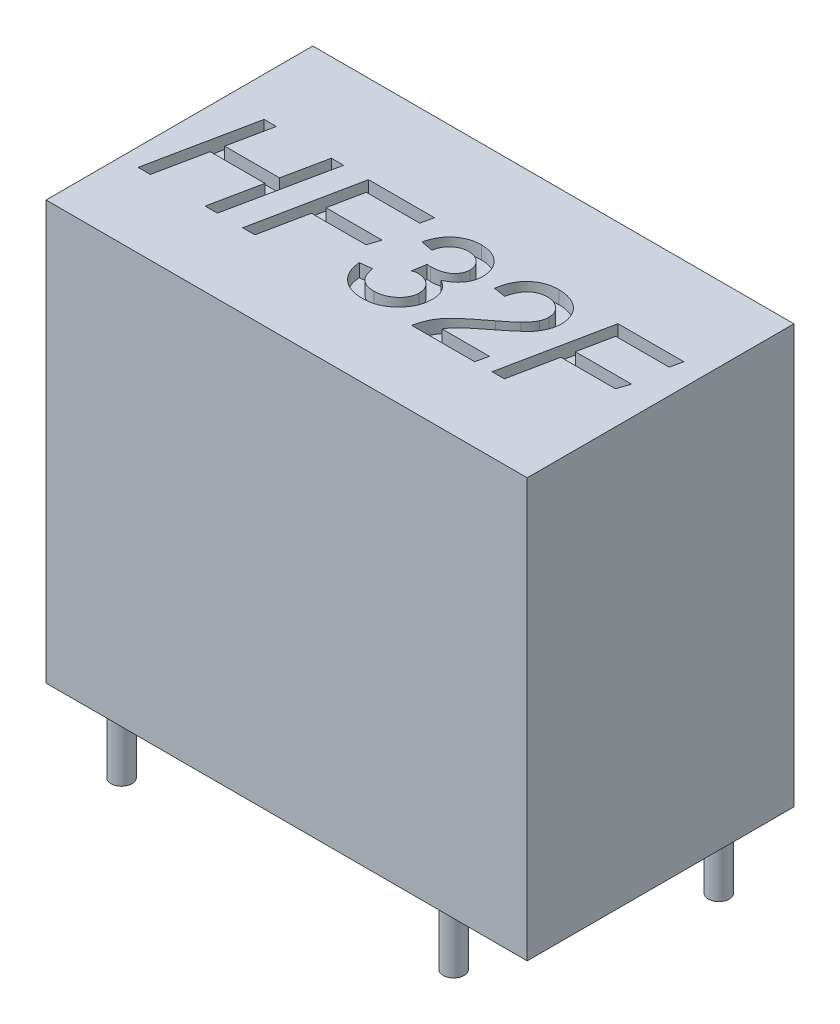
from build123d import *

# Parameters (mm, degrees)
SKETCH_1_W          = 18.4
SKETCH_1_H          = 10.2
EXTRUDE_1_DEPTH     = 16
CUT_EXTRUDE_1_DEPTH = 0.5
SKETCH_3_R          = 0.4
EXTRUDE_2_DEPTH     = 3


with BuildPart() as part:
    # Эскиз1 → Бобышка-Вытянуть1 (new body)
    with BuildSketch(Plane(origin=(0, 0, 0), x_dir=(1, 0, 0), z_dir=(0, 1, 0))):
        with Locations((0.002628925, -0.009178693)):
            Rectangle(SKETCH_1_W, SKETCH_1_H)
    extrude(amount=EXTRUDE_1_DEPTH)

    # Эскиз2 → Вырез-Вытянуть1 (cut)
    with BuildSketch(Plane(origin=(0, 16, 0), x_dir=(1, 0, 0), z_dir=(0, 1, 0))):
        Polygon((-8.518808896, -2.269838225), (-7.698296076, 1.730161775), (-7.228744794, 1.730161775), (-7.565283255, 0.089136134), (-5.466725563, 0.089136134), (-5.126981973, 1.730161775), (-4.656629409, 1.730161775), (-5.48515505, -2.269838225), (-5.954706332, -2.269838225), (-5.562078127, -0.372402328), (-7.659834538, -0.372402328), (-8.049257614, -2.269838225), align=None)
        Polygon((-4.518808896, -2.269838225), (-3.705507614, 1.730161775), (-1.183071717, 1.730161775), (-1.28563582, 1.268623313), (-3.329706332, 1.268623313), (-3.590924281, -0.013427969), (-1.442687102, -0.013427969), (-1.596533255, -0.47496643), (-3.684674281, -0.47496643), (-4.049257614, -2.269838225), align=None)
        with BuildLine():
            Line((-1.134193512, -1.192915148), (-0.67265505, -1.141633097))
            add(Edge.make_bspline(
                [(-0.67265505, -1.141633097), (-0.667779258, -1.172707483), (-0.658342391, -1.232850495), (-0.636985525, -1.318883431), (-0.612595736, -1.398661441), (-0.582937431, -1.471508157), (-0.549446193, -1.537662799), (-0.511411195, -1.59657909), (-0.469972955, -1.649389065), (-0.42270865, -1.694406826), (-0.372127496, -1.733688819), (-0.317892322, -1.768058118), (-0.259188882, -1.795615229), (-0.197296463, -1.818906563), (-0.131756694, -1.837822902), (-0.062160842, -1.849947697), (0.011158673, -1.858546734), (0.061292331, -1.859231315), (0.086960334, -1.859581815)],
                knots=[0, 0, 0, 0, 9.432e-05, 0.000182552, 0.000265677, 0.000344391, 0.000418213, 0.000487782, 0.000554481, 0.000619082, 0.000683034, 0.000746397, 0.000811266, 0.000877195, 0.000944665, 0.001015546, 0.001088901, 0.001165862, 0.001165862, 0.001165862, 0.001165862], degree=3))
            add(Edge.make_bspline(
                [(0.086960334, -1.859581815), (0.117971233, -1.858740567), (0.179393753, -1.857074328), (0.269877404, -1.845991638), (0.357125263, -1.826247232), (0.441392125, -1.800340353), (0.521879545, -1.765293636), (0.599481967, -1.723393912), (0.673783166, -1.673771316), (0.743975314, -1.617099676), (0.807795282, -1.555474714), (0.864664108, -1.491273971), (0.912056607, -1.42417263), (0.952063674, -1.35540452), (0.981469543, -1.283424325), (1.003272201, -1.209922468), (1.017825871, -1.134192797), (1.019040348, -1.082672042), (1.019652642, -1.056697199)],
                knots=[0, 0, 0, 0, 9.3035e-05, 0.000184272, 0.000272922, 0.000361114, 0.000448336, 0.000535819, 0.00062538, 0.000715981, 0.000806085, 0.000891263, 0.00097286, 0.001052171, 0.001129402, 0.00120546, 0.001282003, 0.00135983, 0.00135983, 0.00135983, 0.00135983], degree=3))
            add(Edge.make_bspline(
                [(1.019652642, -1.056697199), (1.018964247, -1.03424059), (1.017614819, -0.990219938), (1.00915351, -0.925566023), (0.992536541, -0.864290472), (0.971011362, -0.805741728), (0.943874553, -0.749631946), (0.908889127, -0.69774322), (0.868484706, -0.648253483), (0.822111792, -0.602361014), (0.771381197, -0.559362881), (0.714588341, -0.524030153), (0.655220466, -0.491693296), (0.590247981, -0.467499338), (0.521849494, -0.447048334), (0.448708779, -0.434049584), (0.371935016, -0.424518122), (0.319097529, -0.423966402), (0.292088539, -0.423684379)],
                knots=[0, 0, 0, 0, 6.7384e-05, 0.00013209, 0.00019506, 0.000257427, 0.000319063, 0.000381512, 0.000444711, 0.000510436, 0.00057702, 0.0006437, 0.000710725, 0.000779472, 0.000851235, 0.000924626, 0.001002052, 0.001083017, 0.001083017, 0.001083017, 0.001083017], degree=3))
            add(Edge.make_bspline(
                [(0.292088539, -0.423684379), (0.284029466, -0.424520767), (0.264339139, -0.426564272), (0.23030911, -0.437746506), (0.185824279, -0.453332787), (0.153119891, -0.467263808), (0.135037257, -0.47496643)],
                knots=[0, 0, 0, 0, 2.4251e-05, 5.9252e-05, 0.000106899, 0.000165825, 0.000165825, 0.000165825, 0.000165825], degree=3))
            Line((0.135037257, -0.47496643), (0.219171873, 0.047469467))
            add(Edge.make_bspline(
                [(0.219171873, 0.047469467), (0.24211381, 0.044665312), (0.287091506, 0.039167762), (0.332393768, 0.038286055), (0.354588539, 0.037854083)],
                knots=[0, 0, 0, 0, 6.9287e-05, 0.000135836, 0.000135836, 0.000135836, 0.000135836], degree=3))
            add(Edge.make_bspline(
                [(0.354588539, 0.037854083), (0.388529215, 0.038489762), (0.454392322, 0.039723322), (0.550230913, 0.048661443), (0.640182759, 0.0630246), (0.724346914, 0.082406251), (0.801955238, 0.109318226), (0.873644436, 0.141335061), (0.93963786, 0.178872125), (0.999152843, 0.222330827), (1.05170769, 0.270236301), (1.097678741, 0.321094127), (1.13754292, 0.374084004), (1.169573105, 0.430067289), (1.194151633, 0.48909149), (1.211211196, 0.550489534), (1.223507927, 0.614561318), (1.224351607, 0.658253122), (1.224780847, 0.680482288)],
                knots=[0, 0, 0, 0, 0.000101813, 0.000197572, 0.000288468, 0.000374954, 0.000456295, 0.000534481, 0.000610213, 0.000683617, 0.000755089, 0.000823165, 0.000889031, 0.000953632, 0.001016132, 0.0010803, 0.001144587, 0.001211171, 0.001211171, 0.001211171, 0.001211171], degree=3))
            add(Edge.make_bspline(
                [(1.224780847, 0.680482288), (1.224008277, 0.700793186), (1.222487739, 0.740768217), (1.215128759, 0.799898013), (1.198962867, 0.855869435), (1.179755581, 0.910188229), (1.152079428, 0.960645245), (1.121663762, 1.010479372), (1.081973736, 1.055474801), (1.039551653, 1.09986163), (0.991791594, 1.138934108), (0.941721084, 1.174553695), (0.887890722, 1.202555483), (0.83228284, 1.227474863), (0.773728571, 1.245266851), (0.712796835, 1.259470494), (0.649137565, 1.267384344), (0.605676874, 1.268207907), (0.583755206, 1.268623313)],
                knots=[0, 0, 0, 0, 6.0982e-05, 0.000120022, 0.000178141, 0.000235442, 0.000292429, 0.000350443, 0.000410154, 0.000471915, 0.000534497, 0.000594955, 0.0006559, 0.000716188, 0.000777516, 0.000839137, 0.000903738, 0.000969487, 0.000969487, 0.000969487, 0.000969487], degree=3))
            add(Edge.make_bspline(
                [(0.583755206, 1.268623313), (0.540829394, 1.266379151), (0.455896165, 1.26193884), (0.331999859, 1.228976302), (0.215650597, 1.172878521), (0.125732451, 1.109895585), (0.059108978, 1.050217018), (0.013864563, 0.999690877), (-0.027232283, 0.945212855), (-0.063185413, 0.885747065), (-0.0944606, 0.821813763), (-0.122087453, 0.753775257), (-0.143301421, 0.680557898), (-0.154256143, 0.630070054), (-0.159834538, 0.604360493)],
                knots=[0, 0, 0, 0, 0.000128695, 0.000254637, 0.000381515, 0.000514444, 0.000582519, 0.000649464, 0.000717573, 0.00078697, 0.000857565, 0.000930921, 0.001006979, 0.001085896, 0.001085896, 0.001085896, 0.001085896], degree=3))
            Line((-0.159834538, 0.604360493), (-0.621372999, 0.692501519))
            add(Edge.make_bspline(
                [(-0.621372999, 0.692501519), (-0.61096151, 0.732722371), (-0.590492442, 0.811796873), (-0.551201033, 0.925388063), (-0.505406839, 1.032132637), (-0.452502903, 1.131511834), (-0.392906746, 1.224362237), (-0.326669698, 1.310161522), (-0.252935731, 1.388233336), (-0.17394489, 1.459705758), (-0.088849448, 1.522794151), (0.000379202, 1.578282798), (0.093124368, 1.62589689), (0.190471656, 1.663683299), (0.291329726, 1.693143414), (0.395768253, 1.714905765), (0.504084795, 1.728152613), (0.577574173, 1.729483766), (0.615005206, 1.730161775)],
                knots=[0, 0, 0, 0, 0.000124601, 0.000244967, 0.000360176, 0.000472733, 0.000582309, 0.000690817, 0.000797391, 0.000904061, 0.001009991, 0.001114717, 0.001218997, 0.001322263, 0.001427488, 0.001533878, 0.001642012, 0.001754263, 0.001754263, 0.001754263, 0.001754263], degree=3))
            add(Edge.make_bspline(
                [(0.615005206, 1.730161775), (0.654046012, 1.729243297), (0.730235989, 1.727450844), (0.841719287, 1.713295648), (0.947628552, 1.691509742), (1.047983024, 1.658996325), (1.142559042, 1.617486863), (1.231309958, 1.566505978), (1.314580879, 1.506982065), (1.390754116, 1.43810079), (1.46010291, 1.36341894), (1.52106292, 1.283736496), (1.570933066, 1.198935497), (1.614719278, 1.111506892), (1.646277877, 1.018324527), (1.669630109, 0.921549287), (1.683486979, 0.820302398), (1.685363078, 0.751571489), (1.686319309, 0.71653998)],
                knots=[0, 0, 0, 0, 0.000117086, 0.000228499, 0.000336621, 0.000441022, 0.000544347, 0.00064592, 0.000747544, 0.00085082, 0.000953449, 0.00105297, 0.001151087, 0.001248204, 0.001345766, 0.001445467, 0.00154655, 0.001651628, 0.001651628, 0.001651628, 0.001651628], degree=3))
            add(Edge.make_bspline(
                [(1.686319309, 0.71653998), (1.685937977, 0.690877125), (1.685189228, 0.640487915), (1.676860683, 0.566001385), (1.663280207, 0.494264648), (1.64480274, 0.424531133), (1.620828833, 0.357574039), (1.591625194, 0.292744355), (1.557484462, 0.230283483), (1.503064725, 0.150669262), (1.423070139, 0.055999685), (1.306576547, -0.045170841), (1.171208738, -0.137176775), (1.070782485, -0.187648959), (1.01885136, -0.213748481)],
                knots=[0, 0, 0, 0, 7.6961e-05, 0.000151113, 0.000224503, 0.000295835, 0.000367307, 0.000437601, 0.000508969, 0.00058053, 0.00072663, 0.000879347, 0.001042029, 0.001216237, 0.001216237, 0.001216237, 0.001216237], degree=3))
            add(Edge.make_bspline(
                [(1.01885136, -0.213748481), (1.055814507, -0.237162615), (1.127544183, -0.282599445), (1.221979032, -0.363846081), (1.302320838, -0.45157464), (1.367944572, -0.54700106), (1.419002138, -0.649781963), (1.454932043, -0.759626488), (1.477382706, -0.87656617), (1.479900007, -0.956966933), (1.481191104, -0.99820361)],
                knots=[0, 0, 0, 0, 0.000131119, 0.000254446, 0.000372434, 0.000487118, 0.000600713, 0.000715498, 0.000832894, 0.000956502, 0.000956502, 0.000956502, 0.000956502], degree=3))
            add(Edge.make_bspline(
                [(1.481191104, -0.99820361), (1.479899638, -1.042066382), (1.477344551, -1.128846231), (1.4587504, -1.25709212), (1.426616022, -1.380561384), (1.38169981, -1.499473514), (1.326240176, -1.614654196), (1.25519967, -1.723842785), (1.173153624, -1.829419187), (1.07957229, -1.92924815), (0.977093993, -2.020272912), (0.869483797, -2.10156848), (0.755801007, -2.168906191), (0.637494414, -2.224496337), (0.514165417, -2.268385235), (0.385632876, -2.298228795), (0.252335889, -2.317471326), (0.161814223, -2.319890651), (0.115806488, -2.321120276)],
                knots=[0, 0, 0, 0, 0.000131567, 0.000260296, 0.000387788, 0.000513551, 0.000641126, 0.000770491, 0.000903525, 0.001041848, 0.001180324, 0.001314299, 0.001445809, 0.001575928, 0.001705936, 0.001837707, 0.001971197, 0.002109166, 0.002109166, 0.002109166, 0.002109166], degree=3))
            add(Edge.make_bspline(
                [(0.115806488, -2.321120276), (0.071696055, -2.320227455), (-0.014898599, -2.318474729), (-0.141420879, -2.303846462), (-0.261575187, -2.27996165), (-0.375072671, -2.246241295), (-0.482081044, -2.203141862), (-0.582241837, -2.149533306), (-0.676307117, -2.087237947), (-0.762750612, -2.014887209), (-0.841235707, -1.934765112), (-0.911283307, -1.84782169), (-0.972537647, -1.754605817), (-1.024057253, -1.654683762), (-1.065607584, -1.548203704), (-1.098615671, -1.435667934), (-1.121941224, -1.316526675), (-1.130054767, -1.234670335), (-1.134193512, -1.192915148)],
                knots=[0, 0, 0, 0, 0.000132299, 0.00025972, 0.000381507, 0.000499394, 0.000614413, 0.00072697, 0.000839644, 0.000952291, 0.001064482, 0.001175607, 0.001286728, 0.001398541, 0.001512221, 0.001629112, 0.001749957, 0.001875786, 0.001875786, 0.001875786, 0.001875786], degree=3))
        make_face()
        with BuildLine():
            add(Edge.make_bspline(
                [(1.942729565, -2.269838225), (1.955993512, -2.212968101), (1.981580444, -2.103262298), (2.033128537, -1.948152448), (2.089012284, -1.806297568), (2.155069415, -1.677399614), (2.231283509, -1.558093354), (2.316648663, -1.442692266), (2.413590394, -1.330713347), (2.505091911, -1.239675551), (2.589316431, -1.163417639), (2.66574369, -1.096346276), (2.756172588, -1.021289853), (2.858236507, -0.935943654), (2.97482154, -0.843534726), (3.103818285, -0.741418538), (3.246439863, -0.631167506), (3.346015534, -0.554793336), (3.39785777, -0.515030533)],
                knots=[0, 0, 0, 0, 0.0001751, 0.000337778, 0.000489846, 0.000632116, 0.000771498, 0.000914128, 0.0010624, 0.00121538, 0.001301027, 0.00140324, 0.001520403, 0.00165357, 0.001802361, 0.001966672, 0.002147144, 0.00234315, 0.00234315, 0.00234315, 0.00234315], degree=3))
            add(Edge.make_bspline(
                [(3.39785777, -0.515030533), (3.429485371, -0.491134353), (3.490403191, -0.445107997), (3.576409187, -0.376505594), (3.655997311, -0.314733624), (3.726622759, -0.2565043), (3.789999282, -0.203703774), (3.845732145, -0.156089229), (3.893806282, -0.113331359), (3.922252019, -0.085637977), (3.935518027, -0.07272284)],
                knots=[0, 0, 0, 0, 0.000118914, 0.00022904, 0.00033003, 0.000421137, 0.000503623, 0.000577497, 0.000641046, 0.000696584, 0.000696584, 0.000696584, 0.000696584], degree=3))
            add(Edge.make_bspline(
                [(3.935518027, -0.07272284), (3.968490359, -0.039109994), (4.032217947, 0.025855553), (4.113753031, 0.129094109), (4.185153877, 0.228751411), (4.220516517, 0.298856046), (4.23760136, 0.332725878)],
                knots=[0, 0, 0, 0, 0.000141137, 0.000272784, 0.00039436, 0.000508001, 0.000508001, 0.000508001, 0.000508001], degree=3))
            add(Edge.make_bspline(
                [(4.23760136, 0.332725878), (4.247526726, 0.355486249), (4.267437145, 0.401143866), (4.286996073, 0.473961047), (4.29947818, 0.549438174), (4.300957038, 0.600837533), (4.301703924, 0.62679639)],
                knots=[0, 0, 0, 0, 7.4399e-05, 0.000149244, 0.000225518, 0.000303345, 0.000303345, 0.000303345, 0.000303345], degree=3))
            add(Edge.make_bspline(
                [(4.301703924, 0.62679639), (4.301106695, 0.648734095), (4.299928177, 0.692023952), (4.290004195, 0.755689135), (4.273976466, 0.816936897), (4.251589618, 0.875617905), (4.222324833, 0.931396366), (4.186830162, 0.984537145), (4.144864699, 1.035191048), (4.097035157, 1.082846315), (4.044883497, 1.126489379), (3.989034284, 1.164575004), (3.930414491, 1.196487982), (3.869231735, 1.223467134), (3.804605239, 1.243286348), (3.737042671, 1.257686944), (3.666525101, 1.266659744), (3.618503584, 1.267962983), (3.594171873, 1.268623313)],
                knots=[0, 0, 0, 0, 6.5783e-05, 0.000129811, 0.000192781, 0.00025543, 0.000317791, 0.000381351, 0.000446806, 0.000514797, 0.000583638, 0.000650534, 0.000717233, 0.000783624, 0.000850783, 0.000919619, 0.00099068, 0.001063668, 0.001063668, 0.001063668, 0.001063668], degree=3))
            add(Edge.make_bspline(
                [(3.594171873, 1.268623313), (3.569836507, 1.267985524), (3.522072857, 1.266733719), (3.451608635, 1.257478924), (3.383370747, 1.243391336), (3.317291921, 1.222493483), (3.254119338, 1.194814908), (3.192460655, 1.162685294), (3.133176631, 1.124384855), (3.077214205, 1.079138837), (3.023412087, 1.028335133), (2.974099384, 0.969951438), (2.928882381, 0.903992774), (2.887339201, 0.831485473), (2.850712171, 0.751265909), (2.816778624, 0.664477805), (2.787374269, 0.570155284), (2.77141917, 0.504297607), (2.763242386, 0.47054639)],
                knots=[0, 0, 0, 0, 7.2987e-05, 0.000143254, 0.000212873, 0.000281802, 0.000350717, 0.000419534, 0.00049021, 0.00056204, 0.00063515, 0.000711894, 0.000790799, 0.000874781, 0.000962253, 0.001055105, 0.001154195, 0.001258362, 0.001258362, 0.001258362, 0.001258362], degree=3))
            Line((2.763242386, 0.47054639), (2.301703924, 0.539456647))
            add(Edge.make_bspline(
                [(2.301703924, 0.539456647), (2.308550888, 0.58444307), (2.321969859, 0.672609372), (2.352393334, 0.800263472), (2.391885284, 0.92056738), (2.439752708, 1.033496514), (2.496341257, 1.139407631), (2.560973134, 1.238289106), (2.635380825, 1.329033957), (2.716861497, 1.412534564), (2.805861634, 1.486945812), (2.900806534, 1.552201923), (3.001102044, 1.607657984), (3.106602563, 1.652761465), (3.217281887, 1.68729426), (3.333154397, 1.711920499), (3.454312827, 1.727725387), (3.536964034, 1.729341072), (3.578947514, 1.730161775)],
                knots=[0, 0, 0, 0, 0.000136472, 0.000267464, 0.000393145, 0.00051593, 0.000634944, 0.000752953, 0.000869712, 0.000986436, 0.001102469, 0.001217154, 0.00133156, 0.001445717, 0.001560773, 0.001678801, 0.001800748, 0.001926642, 0.001926642, 0.001926642, 0.001926642], degree=3))
            add(Edge.make_bspline(
                [(3.578947514, 1.730161775), (3.635155371, 1.728609088), (3.745588199, 1.725558488), (3.90668932, 1.697355319), (4.059917694, 1.652475489), (4.203463765, 1.589459388), (4.334759244, 1.510766343), (4.450537998, 1.417059276), (4.547900488, 1.307631835), (4.625327348, 1.184576446), (4.687109809, 1.054850383), (4.730243852, 0.920558823), (4.758192167, 0.78446912), (4.76156172, 0.692633969), (4.763242386, 0.646828442)],
                knots=[0, 0, 0, 0, 0.0001685, 0.000331056, 0.000489006, 0.000646516, 0.000800014, 0.000946935, 0.001091665, 0.001237254, 0.001381703, 0.001521577, 0.001659551, 0.001796853, 0.001796853, 0.001796853, 0.001796853], degree=3))
            add(Edge.make_bspline(
                [(4.763242386, 0.646828442), (4.762156393, 0.613410496), (4.759976807, 0.546340702), (4.747325002, 0.44615144), (4.724295704, 0.347457867), (4.693896761, 0.249411627), (4.653448995, 0.15257988), (4.604544826, 0.056369268), (4.546628589, -0.038721205), (4.502209536, -0.099475309), (4.479588539, -0.130415148)],
                knots=[0, 0, 0, 0, 0.000100276, 0.000201253, 0.000302332, 0.000403956, 0.000508863, 0.000616727, 0.000727489, 0.000842434, 0.000842434, 0.000842434, 0.000842434], degree=3))
            add(Edge.make_bspline(
                [(4.479588539, -0.130415148), (4.471384856, -0.140363303), (4.453795166, -0.161693352), (4.423943667, -0.194400443), (4.389153154, -0.230941396), (4.348756243, -0.270449376), (4.302516193, -0.312851504), (4.252316933, -0.359666841), (4.195813162, -0.409161487), (4.134728345, -0.46271978), (4.067589567, -0.518923385), (3.995797798, -0.578819288), (3.918802832, -0.642366219), (3.835948197, -0.708743654), (3.748428044, -0.779169708), (3.654844066, -0.852157451), (3.556667957, -0.92895991), (3.489228263, -0.981140799), (3.454748796, -1.007818994)],
                knots=[0, 0, 0, 0, 3.8678e-05, 8.293e-05, 0.000132803, 0.000190032, 0.000252398, 0.000321014, 0.000395942, 0.000477727, 0.000564728, 0.000658601, 0.000758222, 0.000864215, 0.000977091, 0.001095228, 0.001220251, 0.001351037, 0.001351037, 0.001351037, 0.001351037], degree=3))
            add(Edge.make_bspline(
                [(3.454748796, -1.007818994), (3.425332121, -1.030742319), (3.368178562, -1.075279972), (3.285564528, -1.140895834), (3.20904214, -1.203616662), (3.136836552, -1.261549976), (3.072684825, -1.318854241), (3.013038468, -1.371610001), (2.95932028, -1.421008999), (2.897205108, -1.482344918), (2.827899476, -1.554871191), (2.755478806, -1.641287679), (2.692790609, -1.724088317), (2.658620892, -1.781021005), (2.642248796, -1.808299763)],
                knots=[0, 0, 0, 0, 0.000111881, 0.000217374, 0.000316487, 0.000408722, 0.00049503, 0.000574482, 0.000647627, 0.000713921, 0.000836352, 0.000948386, 0.001052074, 0.001147456, 0.001147456, 0.001147456, 0.001147456], degree=3))
            Line((2.642248796, -1.808299763), (4.455550078, -1.808299763))
            Line((4.455550078, -1.808299763), (4.35859495, -2.269838225))
            Line((4.35859495, -2.269838225), (1.942729565, -2.269838225))
        make_face()
        Polygon((5.019652642, -2.269838225), (5.832953924, 1.730161775), (8.355389821, 1.730161775), (8.252825719, 1.268623313), (6.208755206, 1.268623313), (5.947537257, -0.013427969), (8.095774437, -0.013427969), (7.941928283, -0.47496643), (5.853787257, -0.47496643), (5.489203924, -2.269838225), align=None)
    extrude(amount=-CUT_EXTRUDE_1_DEPTH, mode=Mode.SUBTRACT)

    # Эскиз3 → Бобышка-Вытянуть2 (add)
    with BuildSketch(Plane.XZ):
        with Locations((-7.62, 3.8)):
            Circle(SKETCH_3_R)
        with Locations((-7.62, -3.8)):
            Circle(SKETCH_3_R)
        with Locations((5.08, 3.8)):
            Circle(SKETCH_3_R)
        with Locations((7.62, -3.8)):
            Circle(SKETCH_3_R)
    extrude(amount=EXTRUDE_2_DEPTH)


solid = part.part
